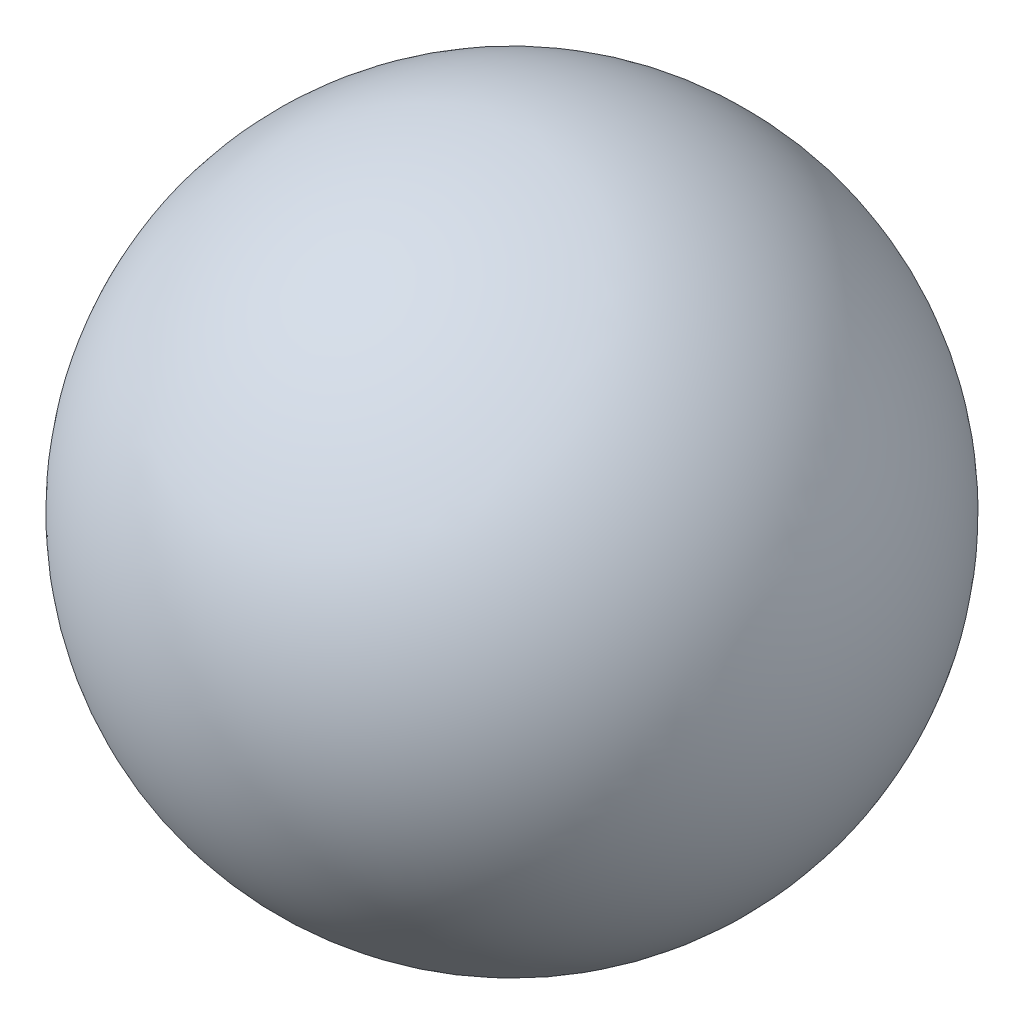
from build123d import *


with BuildPart() as part:
    # Sketch1 → Revolve1 (revolve)
    with BuildSketch(Plane.XY):
        with BuildLine():
            Line((6.8375, 7.325), (3.6625, 7.325))
            ThreePointArc((3.6625, 7.325), (5.25, 8.9125), (6.8375, 7.325))
        make_face()
    revolve(axis=Axis((6.8375, 7.325, 0), (-1, 0, 0)))


solid = part.part
